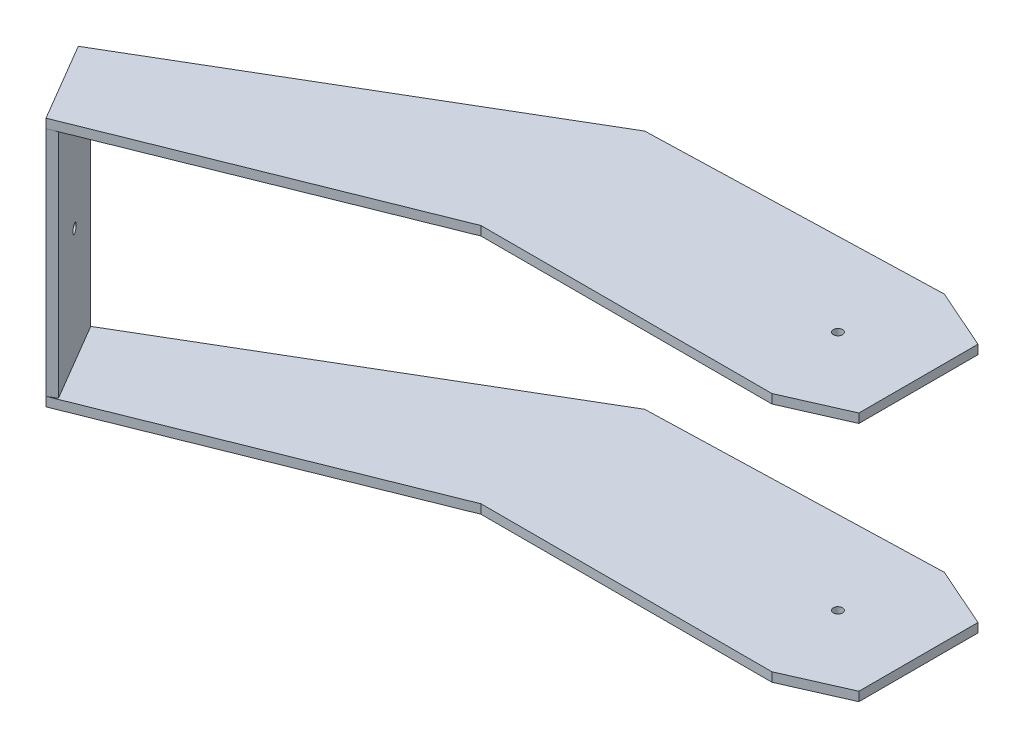
from build123d import *

# Parameters (mm, degrees)
EXTRUDE_3_DEPTH     = 2
SKETCH_5_R          = 1
CUT_EXTRUDE_3_DEPTH = 2
SKETCH_6_W          = 20
SKETCH_6_H          = 55
EXTRUDE_4_DEPTH     = 2
EXTRUDE_5_DEPTH     = 2
SKETCH_9_R          = 1
CUT_EXTRUDE_4_DEPTH = 2
SKETCH_10_R         = 1
CUT_EXTRUDE_5_DEPTH = 2


with BuildPart() as part:
    # 草图3 → 凸台-拉伸3 (new body)
    with BuildSketch(Plane(origin=(0, 25.5, 0), x_dir=(-1, 0, 0), z_dir=(0, -1, 0))):
        Polygon((0, 37.906440796), (-13.266709079, 32.054566719), (-13.266709079, 5.851874077), (0, 0), (64, 0), (132.293984031, -27.379269049), (142.434829102, -10.14084507), (64, 36), align=None)
    extrude(amount=EXTRUDE_3_DEPTH)

    # 草图5 → 切除-拉伸3 (cut)
    with BuildSketch(Plane(origin=(0, 25.5, 0), x_dir=(-1, 0, 0), z_dir=(0, -1, 0))):
        with Locations((4.433290921, 18.953220398)):
            Circle(SKETCH_5_R)
    extrude(amount=CUT_EXTRUDE_3_DEPTH, mode=Mode.SUBTRACT)

    # 草图6 → 凸台-拉伸4 (add)
    with BuildSketch(Plane(origin=(-110.247854089, 0, 64.855488475), x_dir=(0.507042254, 0, 0.861921199), z_dir=(-0.861921199, 0, 0.507042254))):
        with Locations((-53.479867386, -2)):
            Rectangle(SKETCH_6_W, SKETCH_6_H)
    extrude(amount=-EXTRUDE_4_DEPTH)

    # 草图8 → 凸台-拉伸5 (add)
    with BuildSketch(Plane.XZ.offset(29.5)):
        Polygon((0, 0), (-64, 0), (-132.293984031, 27.379269049), (-142.434829102, 10.14084507), (-64, -36), (0, -37.906440796), (13.266709079, -32.054566719), (13.266709079, -5.851874077), align=None)
    extrude(amount=-EXTRUDE_5_DEPTH)

    # 草图9 → 切除-拉伸4 (cut)
    with BuildSketch(Plane.XZ.offset(29.5)):
        with Locations((-4.433290921, -18.953220398)):
            Circle(SKETCH_9_R)
    extrude(amount=-CUT_EXTRUDE_4_DEPTH, mode=Mode.SUBTRACT)

    # 草图10 → 切除-拉伸5 (cut)
    with BuildSketch(Plane(origin=(-110.247854089, 0, 64.855488475), x_dir=(0.507042254, 0, 0.861921199), z_dir=(-0.861921199, 0, 0.507042254))):
        with Locations((-53.479867386, -2)):
            Circle(SKETCH_10_R)
    extrude(amount=-CUT_EXTRUDE_5_DEPTH, mode=Mode.SUBTRACT)


solid = part.part
